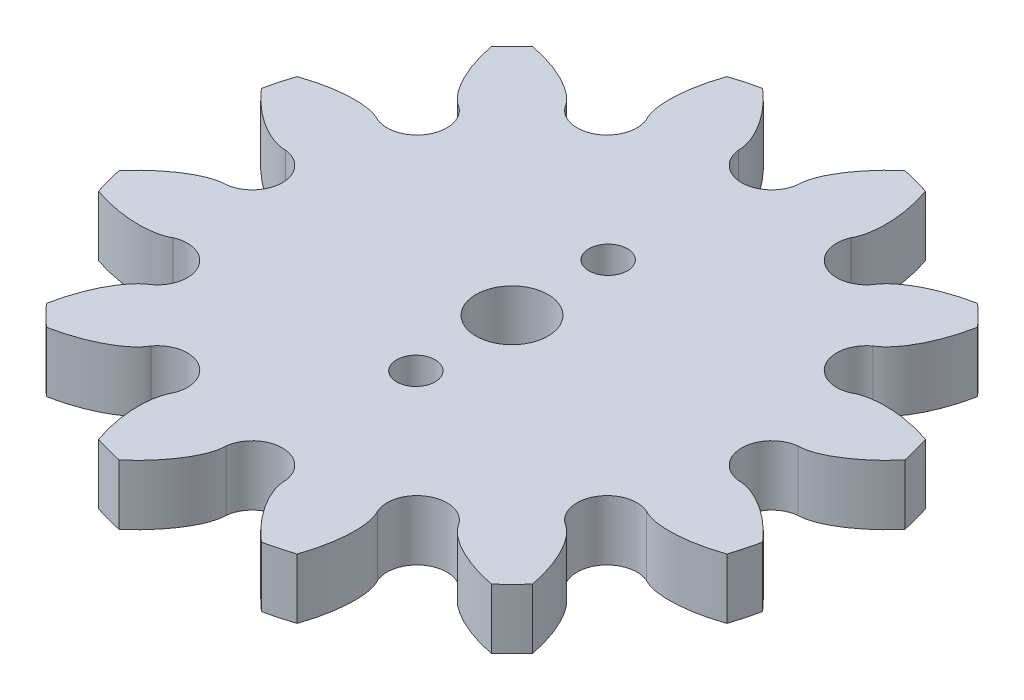
from build123d import *

# Parameters (mm, degrees)
RESSALTO_EXTRUS_O1_DEPTH = 5
ESBO_O3_R                = 3
ESBO_O3_R_2              = 1.6
CORTE_EXTRUS_O1_DEPTH    = 10


with BuildPart() as part:
    # Esboço1 → Ressalto-extrusão1 (new body)
    with BuildSketch(Plane.XZ.offset(5)):
        with BuildLine():
            ThreePointArc((-19.691703555, 75.492649623), (-16.544693651, 74.447916667), (-17.213433323, 71.200159666))
            add(Edge.make_bspline(
                [(-17.213433323, 71.200159666), (-19.371007478, 69.977475346), (-20.225381706, 65.490339119)],
                knots=[3.520301614, 3.520301614, 3.520301614, 4.832179179, 4.832179179, 4.832179179], degree=2, weights=[1, 0.79247571, 1]))
            ThreePointArc((-20.225381706, 65.490339119), (-19.386510918, 64.613489082), (-18.509660881, 63.774618294))
            add(Edge.make_bspline(
                [(-18.509660881, 63.774618294), (-14.022524654, 64.628992522), (-12.799840334, 66.786566677)],
                knots=[4.592598781, 4.592598781, 4.592598781, 5.904476347, 5.904476347, 5.904476347], degree=2, weights=[1, 0.79247571, 1]))
            ThreePointArc((-12.799840334, 66.786566677), (-9.552083333, 67.455306349), (-8.507350377, 64.308296445))
            add(Edge.make_bspline(
                [(-8.507350377, 64.308296445), (-9.764522246, 62.170633685), (-8.260863918, 57.857472608)],
                knots=[0.37870896, 0.37870896, 0.37870896, 1.690586526, 1.690586526, 1.690586526], degree=2, weights=[1, 0.79247571, 1]))
            ThreePointArc((-8.260863918, 57.857472608), (-7.095955487, 57.517533596), (-5.917145685, 57.2294752))
            add(Edge.make_bspline(
                [(-5.917145685, 57.2294752), (-2.458358837, 60.2129531), (-2.478270232, 62.692809289)],
                knots=[4.592598781, 4.592598781, 4.592598781, 5.904476347, 5.904476347, 5.904476347], degree=2, weights=[1, 0.79247571, 1]))
            ThreePointArc((-2.478270232, 62.692809289), (0, 64.895833333), (2.478270232, 62.692809289))
            add(Edge.make_bspline(
                [(2.478270232, 62.692809289), (2.458358837, 60.2129531), (5.917145685, 57.2294752)],
                knots=[3.520301614, 3.520301614, 3.520301614, 4.832179179, 4.832179179, 4.832179179], degree=2, weights=[1, 0.79247571, 1]))
            ThreePointArc((5.917145685, 57.2294752), (7.095955487, 57.517533596), (8.260863918, 57.857472608))
            add(Edge.make_bspline(
                [(8.260863918, 57.857472608), (9.764522246, 62.170633685), (8.507350377, 64.308296445)],
                knots=[4.592598781, 4.592598781, 4.592598781, 5.904476347, 5.904476347, 5.904476347], degree=2, weights=[1, 0.79247571, 1]))
            ThreePointArc((8.507350377, 64.308296445), (9.552083333, 67.455306349), (12.799840334, 66.786566677))
            add(Edge.make_bspline(
                [(12.799840334, 66.786566677), (14.022524654, 64.628992522), (18.509660881, 63.774618294)],
                knots=[3.520301614, 3.520301614, 3.520301614, 4.832179179, 4.832179179, 4.832179179], degree=2, weights=[1, 0.79247571, 1]))
            ThreePointArc((18.509660881, 63.774618294), (19.386510918, 64.613489082), (20.225381706, 65.490339119))
            add(Edge.make_bspline(
                [(20.225381706, 65.490339119), (19.371007478, 69.977475346), (17.213433323, 71.200159666)],
                knots=[4.592598781, 4.592598781, 4.592598781, 5.904476347, 5.904476347, 5.904476347], degree=2, weights=[1, 0.79247571, 1]))
            ThreePointArc((17.213433323, 71.200159666), (16.544693651, 74.447916667), (19.691703555, 75.492649623))
            add(Edge.make_bspline(
                [(19.691703555, 75.492649623), (21.829366315, 74.235477754), (26.142527392, 75.739136082)],
                knots=[3.520301614, 3.520301614, 3.520301614, 4.832179179, 4.832179179, 4.832179179], degree=2, weights=[1, 0.79247571, 1]))
            ThreePointArc((26.142527392, 75.739136082), (26.482466404, 76.904044513), (26.7705248, 78.082854315))
            add(Edge.make_bspline(
                [(26.7705248, 78.082854315), (23.7870469, 81.541641163), (21.307190711, 81.521729768)],
                knots=[4.592598781, 4.592598781, 4.592598781, 5.904476347, 5.904476347, 5.904476347], degree=2, weights=[1, 0.79247571, 1]))
            ThreePointArc((21.307190711, 81.521729768), (19.104166667, 84), (21.307190711, 86.478270232))
            add(Edge.make_bspline(
                [(21.307190711, 86.478270232), (23.7870469, 86.458358837), (26.7705248, 89.917145685)],
                knots=[0.37870896, 0.37870896, 0.37870896, 1.690586526, 1.690586526, 1.690586526], degree=2, weights=[1, 0.79247571, 1]))
            ThreePointArc((26.7705248, 89.917145685), (26.482466404, 91.095955487), (26.142527392, 92.260863918))
            add(Edge.make_bspline(
                [(26.142527392, 92.260863918), (21.829366315, 93.764522246), (19.691703555, 92.507350377)],
                knots=[1.451006128, 1.451006128, 1.451006128, 2.762883693, 2.762883693, 2.762883693], degree=2, weights=[1, 0.79247571, 1]))
            ThreePointArc((19.691703555, 92.507350377), (16.544693651, 93.552083333), (17.213433323, 96.799840334))
            add(Edge.make_bspline(
                [(17.213433323, 96.799840334), (19.371007478, 98.022524654), (20.225381706, 102.509660881)],
                knots=[0.37870896, 0.37870896, 0.37870896, 1.690586526, 1.690586526, 1.690586526], degree=2, weights=[1, 0.79247571, 1]))
            ThreePointArc((20.225381706, 102.509660881), (19.386510918, 103.386510918), (18.509660881, 104.225381706))
            add(Edge.make_bspline(
                [(18.509660881, 104.225381706), (14.022524654, 103.371007478), (12.799840334, 101.213433323)],
                knots=[4.592598781, 4.592598781, 4.592598781, 5.904476347, 5.904476347, 5.904476347], degree=2, weights=[1, 0.79247571, 1]))
            ThreePointArc((12.799840334, 101.213433323), (9.552083333, 100.544693651), (8.507350377, 103.691703555))
            add(Edge.make_bspline(
                [(8.507350377, 103.691703555), (9.764522246, 105.829366315), (8.260863918, 110.142527392)],
                knots=[0.37870896, 0.37870896, 0.37870896, 1.690586526, 1.690586526, 1.690586526], degree=2, weights=[1, 0.79247571, 1]))
            ThreePointArc((8.260863918, 110.142527392), (7.095955487, 110.482466404), (5.917145685, 110.7705248))
            add(Edge.make_bspline(
                [(5.917145685, 110.7705248), (2.458358837, 107.7870469), (2.478270232, 105.307190711)],
                knots=[1.451006128, 1.451006128, 1.451006128, 2.762883693, 2.762883693, 2.762883693], degree=2, weights=[1, 0.79247571, 1]))
            ThreePointArc((2.478270232, 105.307190711), (0, 103.104166667), (-2.478270232, 105.307190711))
            add(Edge.make_bspline(
                [(-2.478270232, 105.307190711), (-2.458358837, 107.7870469), (-5.917145685, 110.7705248)],
                knots=[0.37870896, 0.37870896, 0.37870896, 1.690586526, 1.690586526, 1.690586526], degree=2, weights=[1, 0.79247571, 1]))
            ThreePointArc((-5.917145685, 110.7705248), (-7.095955487, 110.482466404), (-8.260863918, 110.142527392))
            add(Edge.make_bspline(
                [(-8.260863918, 110.142527392), (-9.764522246, 105.829366315), (-8.507350377, 103.691703555)],
                knots=[1.451006128, 1.451006128, 1.451006128, 2.762883693, 2.762883693, 2.762883693], degree=2, weights=[1, 0.79247571, 1]))
            ThreePointArc((-8.507350377, 103.691703555), (-9.552083333, 100.544693651), (-12.799840334, 101.213433323))
            add(Edge.make_bspline(
                [(-12.799840334, 101.213433323), (-14.022524654, 103.371007478), (-18.509660881, 104.225381706)],
                knots=[0.37870896, 0.37870896, 0.37870896, 1.690586526, 1.690586526, 1.690586526], degree=2, weights=[1, 0.79247571, 1]))
            ThreePointArc((-18.509660881, 104.225381706), (-19.386510918, 103.386510918), (-20.225381706, 102.509660881))
            add(Edge.make_bspline(
                [(-20.225381706, 102.509660881), (-19.371007478, 98.022524654), (-17.213433323, 96.799840334)],
                knots=[1.451006128, 1.451006128, 1.451006128, 2.762883693, 2.762883693, 2.762883693], degree=2, weights=[1, 0.79247571, 1]))
            ThreePointArc((-17.213433323, 96.799840334), (-16.544693651, 93.552083333), (-19.691703555, 92.507350377))
            add(Edge.make_bspline(
                [(-19.691703555, 92.507350377), (-21.829366315, 93.764522246), (-26.142527392, 92.260863918)],
                knots=[0.37870896, 0.37870896, 0.37870896, 1.690586526, 1.690586526, 1.690586526], degree=2, weights=[1, 0.79247571, 1]))
            ThreePointArc((-26.142527392, 92.260863918), (-26.482466404, 91.095955487), (-26.7705248, 89.917145685))
            add(Edge.make_bspline(
                [(-26.7705248, 89.917145685), (-23.7870469, 86.458358837), (-21.307190711, 86.478270232)],
                knots=[1.451006128, 1.451006128, 1.451006128, 2.762883693, 2.762883693, 2.762883693], degree=2, weights=[1, 0.79247571, 1]))
            ThreePointArc((-21.307190711, 86.478270232), (-19.104166667, 84), (-21.307190711, 81.521729768))
            add(Edge.make_bspline(
                [(-21.307190711, 81.521729768), (-23.7870469, 81.541641163), (-26.7705248, 78.082854315)],
                knots=[3.520301614, 3.520301614, 3.520301614, 4.832179179, 4.832179179, 4.832179179], degree=2, weights=[1, 0.79247571, 1]))
            ThreePointArc((-26.7705248, 78.082854315), (-26.482466404, 76.904044513), (-26.142527392, 75.739136082))
            add(Edge.make_bspline(
                [(-26.142527392, 75.739136082), (-21.829366315, 74.235477754), (-19.691703555, 75.492649623)],
                knots=[4.592598781, 4.592598781, 4.592598781, 5.904476347, 5.904476347, 5.904476347], degree=2, weights=[1, 0.79247571, 1]))
        make_face()
    extrude(amount=-RESSALTO_EXTRUS_O1_DEPTH)

    # Esboço3 → Corte-extrusão1 (cut)
    with BuildSketch(Plane.XZ.offset(5)):
        with Locations((0, 84)):
            Circle(ESBO_O3_R)
        with Locations((0, 92)):
            Circle(ESBO_O3_R_2)
        with Locations((0, 76)):
            Circle(ESBO_O3_R_2)
    extrude(amount=-CORTE_EXTRUS_O1_DEPTH, mode=Mode.SUBTRACT)


solid = part.part
